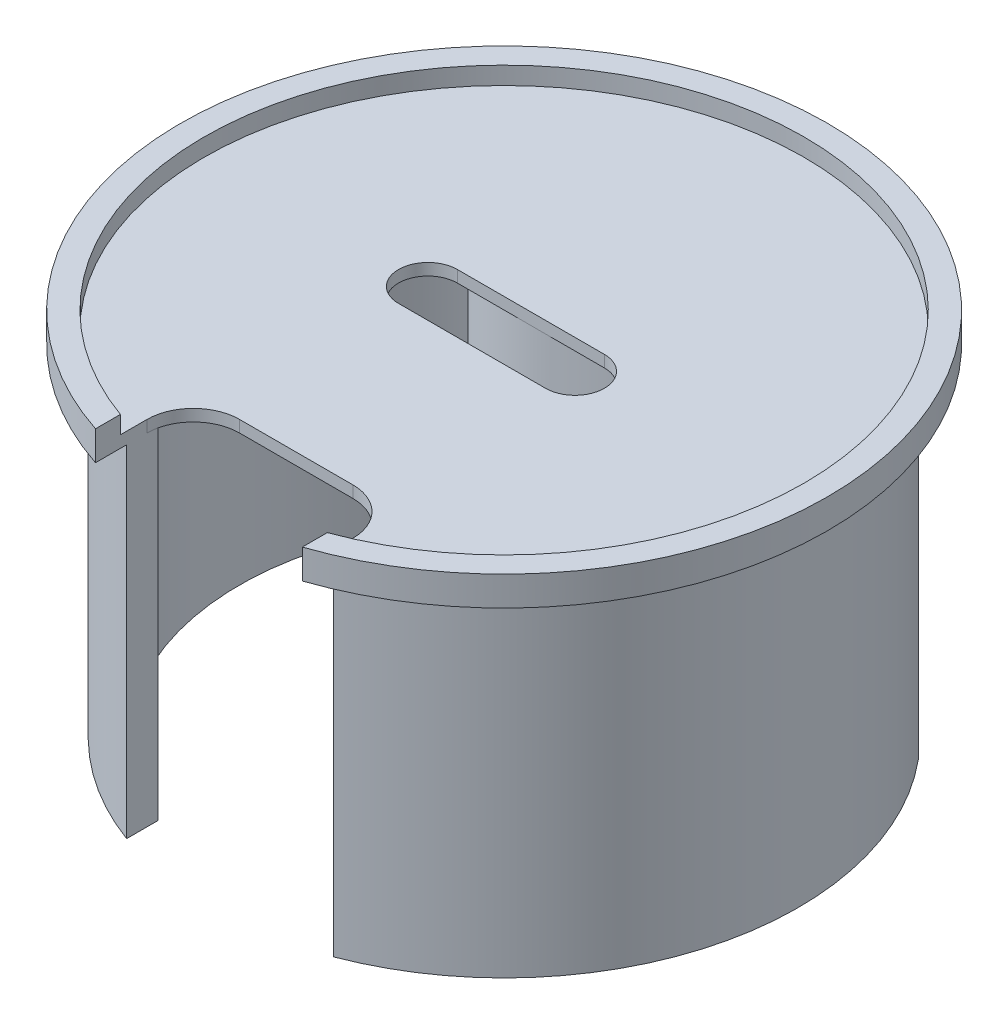
from build123d import *

# Parameters (mm, degrees)
SKETCH3_R           = 69.85
BOSS_EXTRUDE1_DEPTH = 6.35
SKETCH4_R           = 64.77
CUT_EXTRUDE1_DEPTH  = 3.81
SKETCH5_W           = 44.45
SKETCH5_H           = 25.4
CUT_EXTRUDE2_DEPTH  = 7.35
FILLET1_R           = 10
BOSS_EXTRUDE2_DEPTH = 31.75
BOSS_EXTRUDE3_DEPTH = 76.2


with BuildPart() as part:
    # Sketch3 → Boss-Extrude1 (new body)
    with BuildSketch(Plane(origin=(0, 0, 0), x_dir=(1, 0, 0), z_dir=(0, 1, 0))):
        Circle(SKETCH3_R)
        with BuildLine():
            Line((-16.448489627, 6.35), (15.301510373, 6.35))
            ThreePointArc((15.301510373, 6.35), (21.651510373, 0), (15.301510373, -6.35))
            Line((15.301510373, -6.35), (-16.448489627, -6.35))
            ThreePointArc((-16.448489627, -6.35), (-22.798489627, 0), (-16.448489627, 6.35))
        make_face(mode=Mode.SUBTRACT)
    extrude(amount=BOSS_EXTRUDE1_DEPTH)

    # Sketch4 → Cut-Extrude1 (cut)
    with BuildSketch(Plane(origin=(0, 6.35, 0), x_dir=(1, 0, 0), z_dir=(0, 1, 0))):
        Circle(SKETCH4_R)
    extrude(amount=-CUT_EXTRUDE1_DEPTH, mode=Mode.SUBTRACT)

    # Sketch5 → Cut-Extrude2 (cut, through all)
    with BuildSketch(Plane(origin=(0, 6.35, 0), x_dir=(1, 0, 0), z_dir=(0, 1, 0))):
        with Locations((0.312165283, -57.905331129)):
            Rectangle(SKETCH5_W, SKETCH5_H)
    extrude(amount=-CUT_EXTRUDE2_DEPTH, mode=Mode.SUBTRACT)

    # Fillet1
    fillet1_edges = [part.edges().sort_by_distance(p)[0] for p in [
        (22.537165283, 1.27, 45.205331129),
        (-21.912834717, 1.27, 45.205331129),
    ]]
    fillet(fillet1_edges, radius=FILLET1_R)

    # Sketch8 → Boss-Extrude2 (add)
    with BuildSketch(Plane.XZ):
        with BuildLine():
            Line((34.258206884, -40.64), (30.448206884, -40.64))
            ThreePointArc((30.448206884, -40.64), (0, -10.191793116), (-30.448206884, -40.64))
            Line((-30.448206884, -40.64), (-34.258206884, -40.64))
            ThreePointArc((-34.258206884, -40.64), (0, -6.381793116), (34.258206884, -40.64))
        make_face()
    extrude(amount=BOSS_EXTRUDE2_DEPTH)

    # Sketch11 → Boss-Extrude3 (add)
    with BuildSketch(Plane(origin=(0, 2.54, 0), x_dir=(1, 0, 0), z_dir=(0, 1, 0))):
        with BuildLine():
            ThreePointArc((-21.912834717, -52.782100893), (-56.087729184, -10.967640358), (-40.18100173, 40.64))
            Line((-40.18100173, 40.64), (-48.791806689, 40.64))
            ThreePointArc((-48.791806689, 40.64), (-61.333240284, -16.446386725), (-21.912834717, -59.599309347))
            Line((-21.912834717, -59.599309347), (-21.912834717, -55.205331129))
            Line((-21.912834717, -55.205331129), (-21.912834717, -52.782100893))
        make_face()
        with BuildLine():
            Line((48.791806689, 40.64), (40.18100173, 40.64))
            ThreePointArc((40.18100173, 40.64), (56.15176968, -10.634907703), (22.537165283, -52.518555588))
            Line((22.537165283, -52.518555588), (22.537165283, -55.205331129))
            Line((22.537165283, -55.205331129), (22.537165283, -59.366035584))
            ThreePointArc((22.537165283, -59.366035584), (61.418705204, -16.124287613), (48.791806689, 40.64))
        make_face()
    extrude(amount=-BOSS_EXTRUDE3_DEPTH)


solid = part.part
